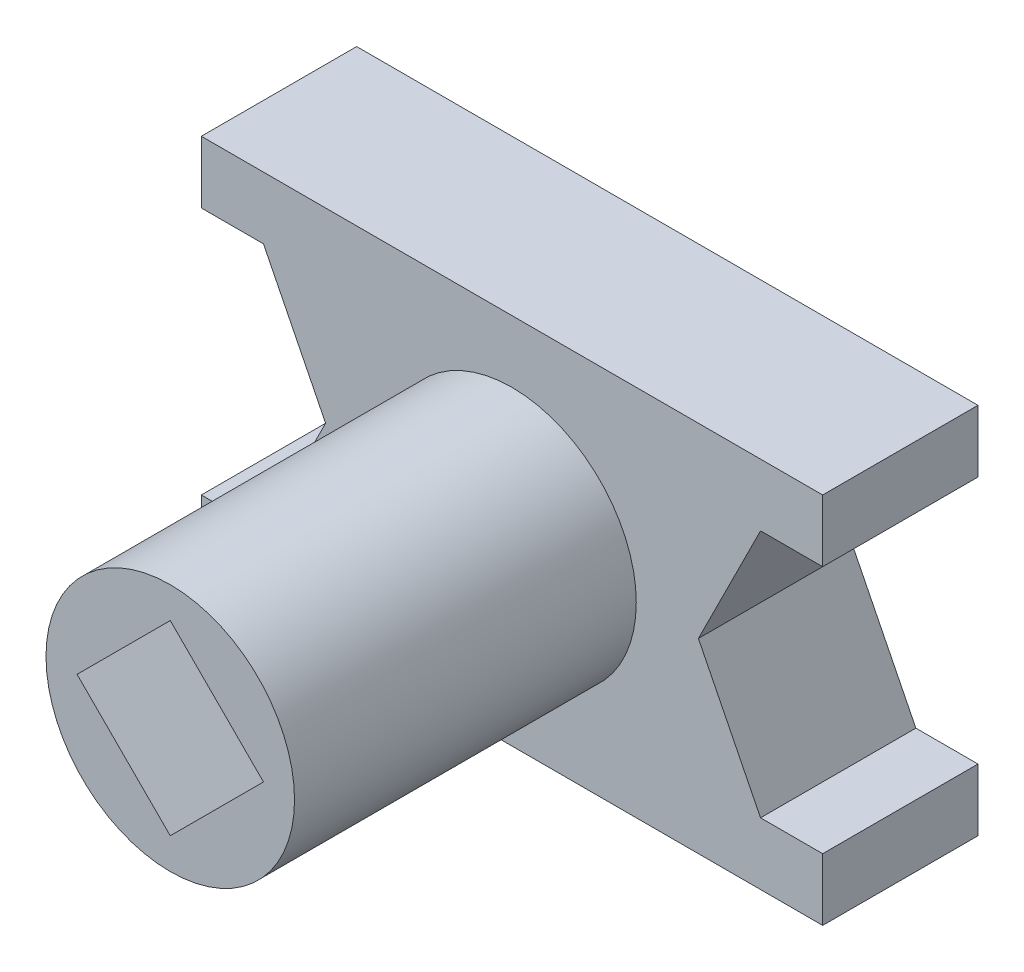
from build123d import *

# Parameters (mm, degrees)
EXTRUDE_1_DEPTH     = 25
SKETCH_2_R          = 20
EXTRUDE_2_DEPTH     = 55
CUT_EXTRUDE_1_DEPTH = 40
SKETCH_4_R          = 8
CUT_EXTRUDE_2_DEPTH = 40


with BuildPart() as part:
    # Эскиз1 → Бобышка-Вытянуть1 (new body)
    with BuildSketch(Plane.XY):
        Polygon((50, -30), (-50, -30), (-50, -20), (-40, -20), (-30, 0), (-40, 20), (-50, 20), (-50, 30), (50, 30), (50, 20), (40, 20), (30, 0), (40, -20), (50, -20), align=None)
    extrude(amount=EXTRUDE_1_DEPTH)

    # Эскиз2 → Бобышка-Вытянуть2 (add)
    with BuildSketch(Plane.XY.offset(25)):
        Circle(SKETCH_2_R)
    extrude(amount=EXTRUDE_2_DEPTH)

    # Эскиз3 → Вырез-Вытянуть1 (cut)
    with BuildSketch(Plane.XY.offset(80)):
        Polygon((15, 0), (0, -15), (-15, 0), (0, 15), align=None)
    extrude(amount=-CUT_EXTRUDE_1_DEPTH, mode=Mode.SUBTRACT)

    # Эскиз4 → Вырез-Вытянуть2 (cut)
    with BuildSketch(Plane.XY.offset(40)):
        Circle(SKETCH_4_R)
    extrude(amount=-CUT_EXTRUDE_2_DEPTH, mode=Mode.SUBTRACT)


solid = part.part
